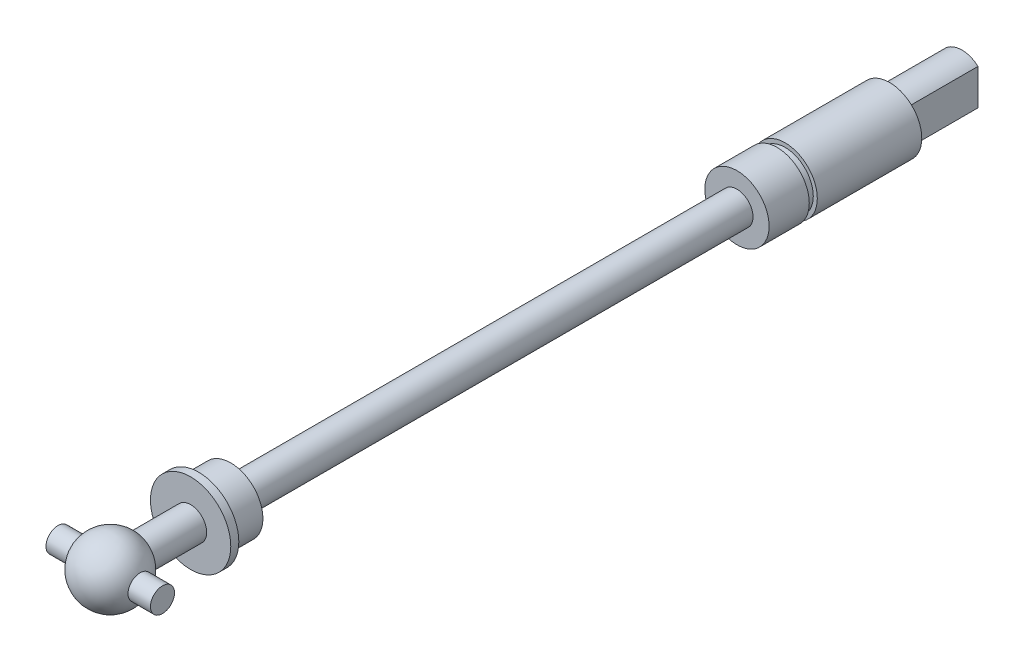
from build123d import *

# Parameters (mm, degrees)
CUT_EXTRUDE1_DEPTH  = 9
SKETCH3_R           = 1.5
BOSS_EXTRUDE1_DEPTH = 6.5


with BuildPart() as part:
    # Sketch1 → Revolve1 (revolve)
    with BuildSketch(Plane(origin=(0, 0, 0), x_dir=(0, 0, -1), z_dir=(1, 0, 0))):
        with BuildLine():
            Line((7.464101615, 2), (14, 2))
            Line((14, 2), (14, 5))
            Line((14, 5), (15, 5))
            Line((15, 5), (15, 4))
            Line((15, 4), (19, 4))
            Line((19, 4), (19, 2))
            Line((19, 2), (82, 2))
            Line((82, 2), (82, 4))
            Line((82, 4), (87, 4))
            Line((87, 4), (87, 3.5))
            Line((87, 3.5), (88, 3.5))
            Line((88, 3.5), (88, 4))
            Line((88, 4), (101, 4))
            Line((101, 4), (101, 3))
            Line((101, 3), (110, 3))
            Line((110, 3), (110, 0))
            Line((110, 0), (0, 0))
            ThreePointArc((0, 0), (2.96472382, 3.863703305), (7.464101615, 2))
        make_face()
    revolve(axis=Axis((0, 0, 0), (0, 0, -1)))

    # Sketch2 → Cut-Extrude1 (cut)
    with BuildSketch(Plane(origin=(0, 0, -110), x_dir=(-1, 0, 0), z_dir=(0, 0, -1))):
        with BuildLine():
            ThreePointArc((-2, 2.236067977), (-3, 0), (-2, -2.236067977))
            Line((-2, -2.236067977), (-2, 2.236067977))
        make_face()
        with BuildLine():
            Line((2, 2.236067977), (2, -2.236067977))
            ThreePointArc((2, -2.236067977), (2.738612788, -1.224744871), (3, 0))
            ThreePointArc((3, 0), (2.738612788, 1.224744871), (2, 2.236067977))
        make_face()
    extrude(amount=-CUT_EXTRUDE1_DEPTH, mode=Mode.SUBTRACT)

    # Sketch3 → Boss-Extrude1 (add, symmetric)
    with BuildSketch(Plane(origin=(0, 0, 0), x_dir=(0, 0, -1), z_dir=(1, 0, 0))):
        with Locations((4, 0)):
            Circle(SKETCH3_R)
    extrude(amount=BOSS_EXTRUDE1_DEPTH, both=True)


solid = part.part
